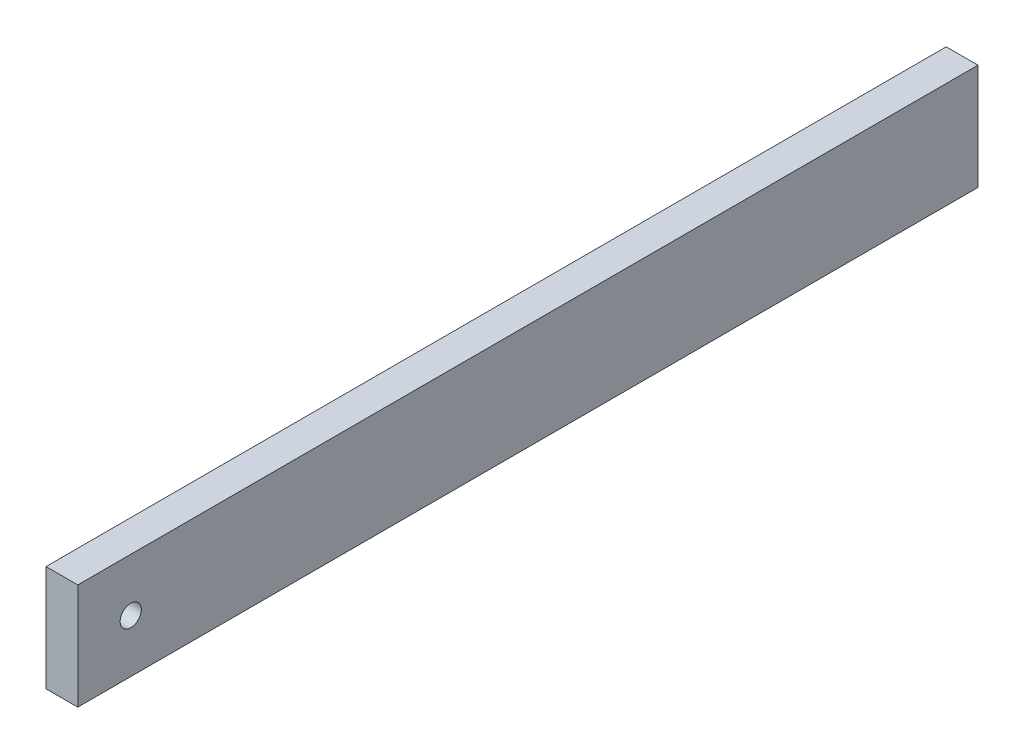
from build123d import *

# Parameters (mm, degrees)
ESQUISSE1_W        = 85
ESQUISSE1_H        = 10
ESQUISSE1_R        = 1
BOSS_EXTRU_1_DEPTH = 3


with BuildPart() as part:
    # Esquisse1 → Boss.-Extru.1 (new body)
    with BuildSketch(Plane(origin=(0, 0, 0), x_dir=(0, 0, -1), z_dir=(1, 0, 0))):
        with Locations((42.5, 5)):
            Rectangle(ESQUISSE1_W, ESQUISSE1_H)
        with Locations((5, 5)):
            Circle(ESQUISSE1_R, mode=Mode.SUBTRACT)
    extrude(amount=BOSS_EXTRU_1_DEPTH)


solid = part.part
